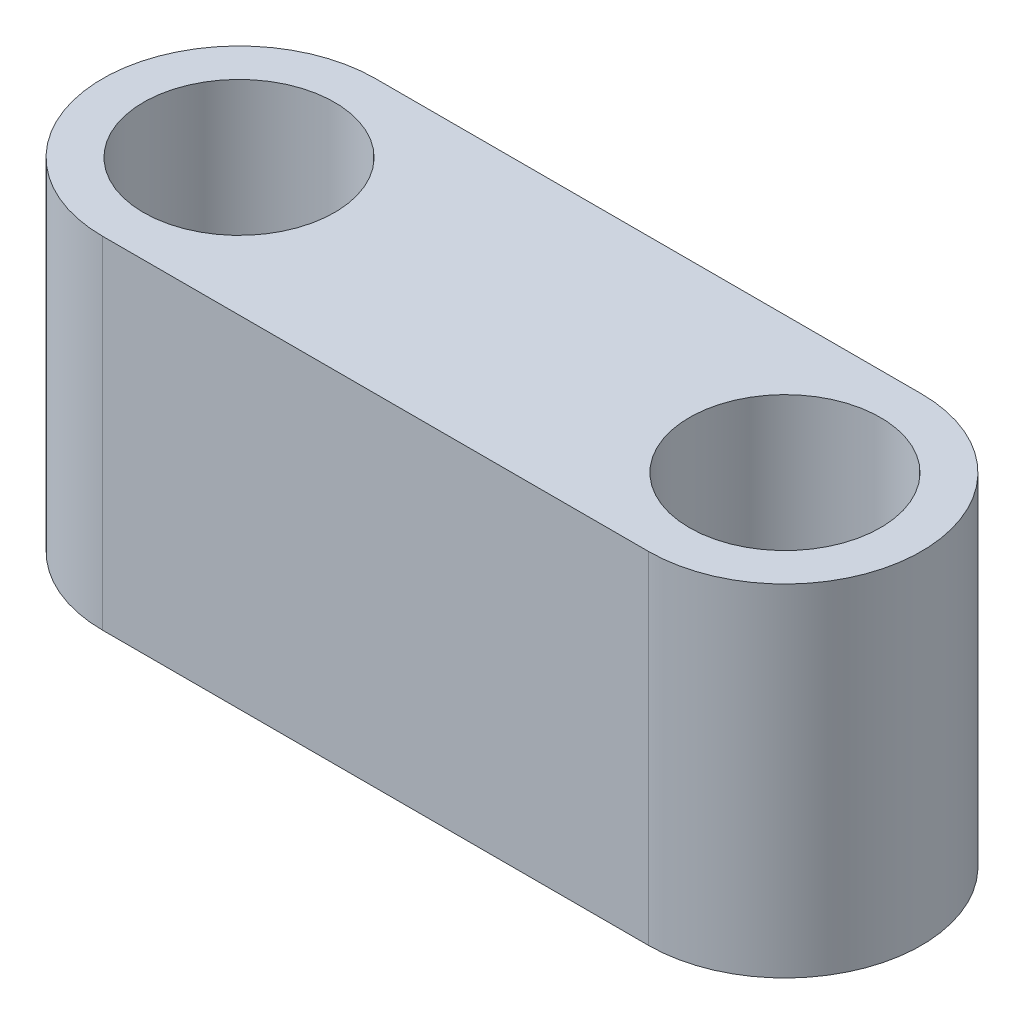
from build123d import *

# Parameters (mm, degrees)
SKETCH1_R           = 14
BOSS_EXTRUDE1_DEPTH = 50


with BuildPart() as part:
    # Sketch1 → Boss-Extrude1 (new body)
    with BuildSketch(Plane(origin=(0, 0, 0), x_dir=(1, 0, 0), z_dir=(0, 1, 0))):
        with BuildLine():
            Line((-40, 20), (40, 20))
            ThreePointArc((40, 20), (60, 0), (40, -20))
            Line((40, -20), (-40, -20))
            ThreePointArc((-40, -20), (-60, 0), (-40, 20))
        make_face()
        with Locations((40, 0)):
            Circle(SKETCH1_R, mode=Mode.SUBTRACT)
        with Locations((-40, 0)):
            Circle(SKETCH1_R, mode=Mode.SUBTRACT)
    extrude(amount=BOSS_EXTRUDE1_DEPTH)


solid = part.part
